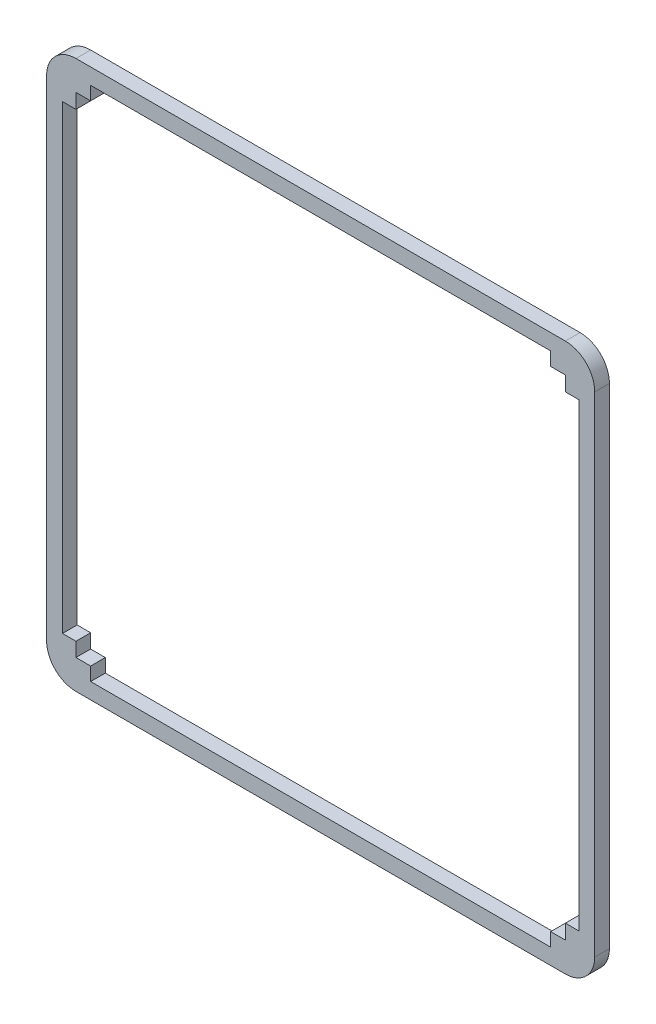
from build123d import *

# Parameters (mm, degrees)
EXTRUDE_1_DEPTH = 3


with BuildPart() as part:
    # 草图1 → 凸台-拉伸1 (new body)
    with BuildSketch(Plane.XY):
        with BuildLine():
            ThreePointArc((-6, 0), (-4.242640687, -4.242640687), (0, -6))
            Line((0, -6), (100, -6))
            ThreePointArc((100, -6), (104.242640687, -4.242640687), (106, 0))
            Line((106, 0), (106, 100))
            ThreePointArc((106, 100), (104.242640687, 104.242640687), (100, 106))
            Line((100, 106), (0, 106))
            ThreePointArc((0, 106), (-4.242640687, 104.242640687), (-6, 100))
            Line((-6, 100), (-6, 0))
        make_face()
        Polygon((97, 0), (97, -2.75), (3, -2.75), (3, 0), (0, 0), (0, 2.885491928), (-2.75, 2.885491928), (-2.75, 3.015491928), (-2.75, 97), (0, 97), (0, 100), (3, 100), (3, 102.75), (97, 102.75), (97, 100), (100, 100), (100, 97), (102.75, 97), (102.75, 3), (100, 3), (100, 0), align=None, mode=Mode.SUBTRACT)
    extrude(amount=EXTRUDE_1_DEPTH)


solid = part.part
